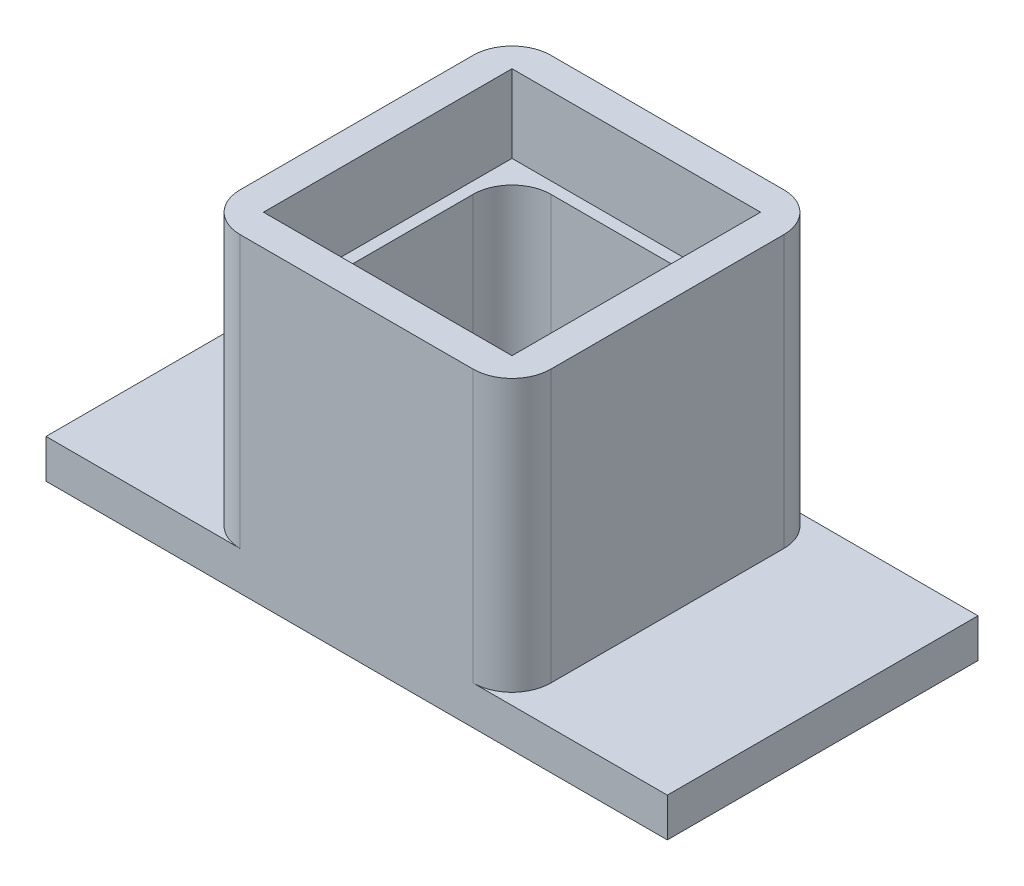
from build123d import *

# Parameters (mm, degrees)
SKETCH1_W           = 40
SKETCH1_H           = 40
SKETCH1_W_2         = 29
SKETCH1_H_2         = 29
BOSS_EXTRUDE1_DEPTH = 25
SKETCH2_W           = 40
SKETCH2_H           = 40
SKETCH2_W_2         = 32
SKETCH2_H_2         = 32
BOSS_EXTRUDE2_DEPTH = 10
SKETCH4_W           = 80
SKETCH4_H           = 40
SKETCH4_W_2         = 29
SKETCH4_H_2         = 29
BOSS_EXTRUDE3_DEPTH = 5
FILLET6_R           = 5


with BuildPart() as part:
    # Sketch1 → Boss-Extrude1 (new body)
    with BuildSketch(Plane(origin=(0, 0, 0), x_dir=(1, 0, 0), z_dir=(0, 1, 0))):
        with Locations((20, 20)):
            Rectangle(SKETCH1_W, SKETCH1_H)
        with Locations((20, 20)):
            Rectangle(SKETCH1_W_2, SKETCH1_H_2, mode=Mode.SUBTRACT)
    extrude(amount=BOSS_EXTRUDE1_DEPTH)

    # Sketch2 → Boss-Extrude2 (add)
    with BuildSketch(Plane(origin=(0, 25, 0), x_dir=(1, 0, 0), z_dir=(0, 1, 0))):
        with Locations((20, 20)):
            Rectangle(SKETCH2_W, SKETCH2_H)
        with Locations((20, 20)):
            Rectangle(SKETCH2_W_2, SKETCH2_H_2, mode=Mode.SUBTRACT)
    extrude(amount=BOSS_EXTRUDE2_DEPTH)

    # Sketch4 → Boss-Extrude3 (add)
    with BuildSketch(Plane.XZ):
        with Locations((20, -20)):
            Rectangle(SKETCH4_W, SKETCH4_H)
        with Locations((20, -20)):
            Rectangle(SKETCH4_W_2, SKETCH4_H_2, mode=Mode.SUBTRACT)
    extrude(amount=BOSS_EXTRUDE3_DEPTH)

    # Fillet6
    fillet6_edges = [part.edges().sort_by_distance(p)[0] for p in [
        (5.5, 10, -5.5),
        (34.5, 10, -5.5),
        (34.5, 10, -34.5),
        (5.5, 10, -34.5),
        (0, 17.5, -40),
        (40, 17.5, -40),
        (40, 17.5, 0),
        (0, 17.5, 0),
    ]]
    fillet(fillet6_edges, radius=FILLET6_R)


solid = part.part
